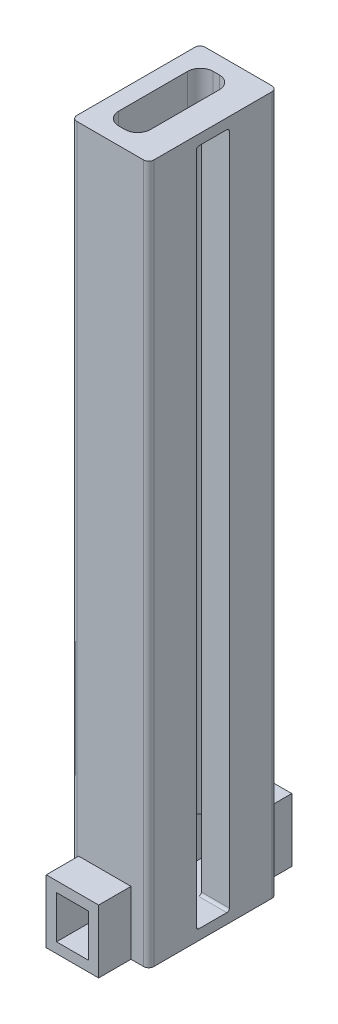
from build123d import *

# Parameters (mm, degrees)
BOSS_EXTRUDE2_DEPTH  = 134
BOSS_EXTRUDE3_DEPTH  = 2
SKETCH18_W           = 5.45
SKETCH18_H           = 6.4
BOSS_EXTRUDE10_DEPTH = 2
FILLET1_R            = 0.5
FILLET2_R            = 0.5
SKETCH45_W           = 6.2
SKETCH45_H           = 8.3
CUT_EXTRUDE6_DEPTH   = 32.3
BOSS_EXTRUDE11_DEPTH = 6.3


with BuildPart() as part:
    # Sketch3 → Boss-Extrude2 (new body)
    with BuildSketch(Plane(origin=(0, 0, 0), x_dir=(1, 0, 0), z_dir=(0, 1, 0))):
        with BuildLine():
            Line((0, -11.5), (0, 11.5))
            ThreePointArc((0, 11.5), (0.292893219, 12.207106781), (1, 12.5))
            Line((1, 12.5), (14, 12.5))
            ThreePointArc((14, 12.5), (14.707106781, 12.207106781), (15, 11.5))
            Line((15, 11.5), (15, 3.2))
            Line((15, 3.2), (9.55, 3.2))
            Line((9.55, 3.2), (9.55, 6.7))
            ThreePointArc((9.55, 6.7), (8.817766953, 8.467766953), (7.05, 9.2))
            Line((7.05, 9.2), (5.85, 9.2))
            ThreePointArc((5.85, 9.2), (4.082233047, 8.467766953), (3.35, 6.7))
            Line((3.35, 6.7), (3.35, -6.7))
            ThreePointArc((3.35, -6.7), (4.082233047, -8.467766953), (5.85, -9.2))
            Line((5.85, -9.2), (7.05, -9.2))
            ThreePointArc((7.05, -9.2), (8.817766953, -8.467766953), (9.55, -6.7))
            Line((9.55, -6.7), (9.55, -3.2))
            Line((9.55, -3.2), (15, -3.2))
            Line((15, -3.2), (15, -11.5))
            ThreePointArc((15, -11.5), (14.707106781, -12.207106781), (14, -12.5))
            Line((14, -12.5), (1, -12.5))
            ThreePointArc((1, -12.5), (0.292893219, -12.207106781), (0, -11.5))
        make_face()
    extrude(amount=BOSS_EXTRUDE2_DEPTH)

    # Sketch6 → Boss-Extrude3 (add)
    with BuildSketch(Plane.XZ):
        with BuildLine():
            Line((1, 12.5), (3.35, 12.5))
            Line((3.35, 12.5), (3.35, 18.8))
            Line((3.35, 18.8), (9.55, 18.8))
            Line((9.55, 18.8), (9.55, 12.5))
            Line((9.55, 12.5), (14, 12.5))
            ThreePointArc((14, 12.5), (14.707106781, 12.207106781), (15, 11.5))
            Line((15, 11.5), (15, -11.5))
            ThreePointArc((15, -11.5), (14.707106781, -12.207106781), (14, -12.5))
            Line((14, -12.5), (9.55, -12.5))
            Line((9.55, -12.5), (9.55, -18.8))
            Line((9.55, -18.8), (3.35, -18.8))
            Line((3.35, -18.8), (3.35, -12.5))
            Line((3.35, -12.5), (1, -12.5))
            ThreePointArc((1, -12.5), (0.292893219, -12.207106781), (0, -11.5))
            Line((0, -11.5), (0, 11.5))
            ThreePointArc((0, 11.5), (0.292893219, 12.207106781), (1, 12.5))
        make_face()
    extrude(amount=BOSS_EXTRUDE3_DEPTH)

    # Sketch18 → Boss-Extrude10 (add)
    with BuildSketch(Plane(origin=(0, 134, 0), x_dir=(1, 0, 0), z_dir=(0, 1, 0))):
        with Locations((12.275, 0)):
            Rectangle(SKETCH18_W, SKETCH18_H)
    extrude(amount=-BOSS_EXTRUDE10_DEPTH)

    # Fillet1
    fillet1_edges = [part.edges().sort_by_distance(p)[0] for p in [
        (12.275, 132, 3.2),
    ]]
    fillet(fillet1_edges, radius=FILLET1_R)

    # Fillet2
    fillet2_edges = [part.edges().sort_by_distance(p)[0] for p in [
        (12.275, 132, -3.2),
        (12.275, 0, -3.2),
        (12.275, 0, 3.2),
    ]]
    fillet(fillet2_edges, radius=FILLET2_R)

    # Sketch45 → Cut-Extrude6 (cut, through all)
    with BuildSketch(Plane(origin=(0, 0, -12.5), x_dir=(-1, 0, 0), z_dir=(0, 0, -1))):
        with Locations((-6.45, 4.15)):
            Rectangle(SKETCH45_W, SKETCH45_H)
    extrude(amount=-CUT_EXTRUDE6_DEPTH, mode=Mode.SUBTRACT)

    # Sketch46 → Boss-Extrude11 (add)
    with BuildSketch(Plane(origin=(0, 0, -12.5), x_dir=(-1, 0, 0), z_dir=(0, 0, -1))):
        Polygon((-9.55, -2), (-9.55, 8.3), (-3.35, 8.3), (-3.35, -2), (-1.35, -2), (-1.35, 10.3), (-11.55, 10.3), (-11.55, -2), align=None)
    boss_extrude11 = extrude(amount=BOSS_EXTRUDE11_DEPTH)

    # Mirror1: Boss-Extrude11 across plane
    add(boss_extrude11.mirror(Plane(origin=(0, 0, 0), x_dir=(1, 0, 0), z_dir=(0, 0, -1))))


solid = part.part
